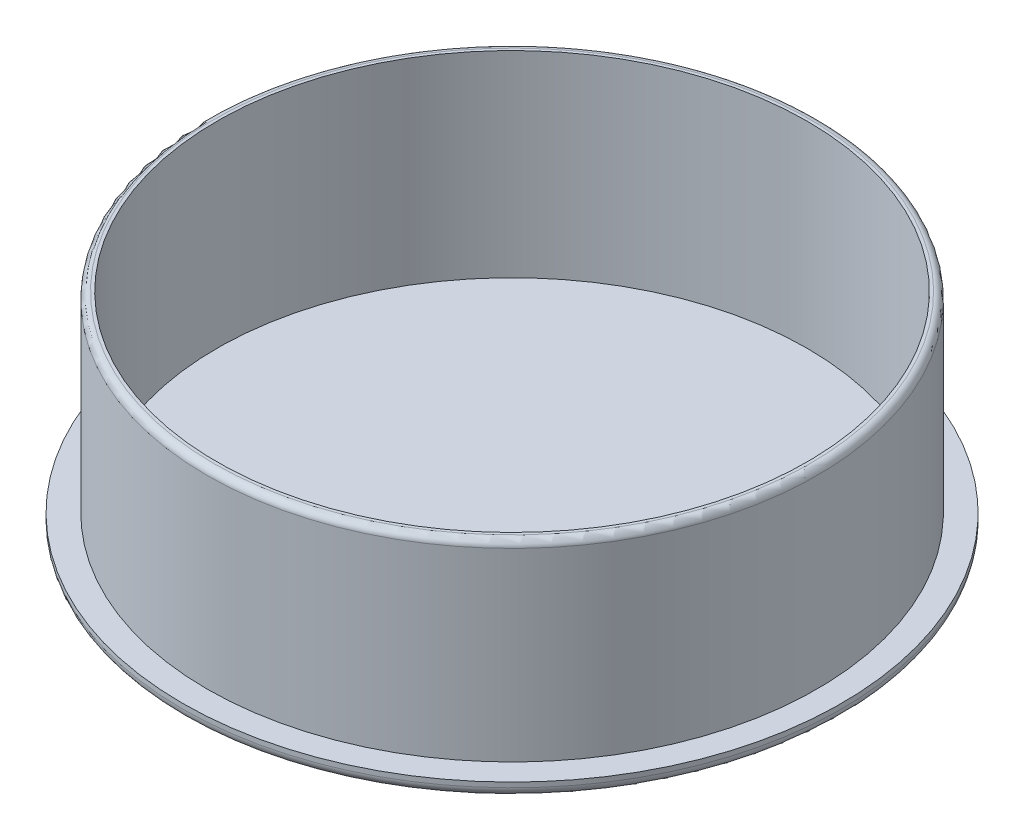
from build123d import *

# Parameters (mm, degrees)
SKETCH1_R           = 62
BOSS_EXTRUDE1_DEPTH = 42
SKETCH2_R           = 67
BOSS_EXTRUDE2_DEPTH = 3
FILLET1_R           = 2
SHELL1_T            = -2
FILLET2_R           = 1.4


with BuildPart() as part:
    # Sketch1 → Boss-Extrude1 (new body)
    with BuildSketch(Plane(origin=(0, 0, 0), x_dir=(1, 0, 0), z_dir=(0, 1, 0))):
        with Locations(Location((0, 0, 0), (0, 0, 90))):
            Circle(SKETCH1_R)
    extrude(amount=BOSS_EXTRUDE1_DEPTH)

    # Sketch2 → Boss-Extrude2 (add)
    with BuildSketch(Plane(origin=(0, 0, 0), x_dir=(1, 0, 0), z_dir=(0, 1, 0))):
        with Locations(Location((0, 0, 0), (0, 0, 270))):
            Circle(SKETCH2_R)
    extrude(amount=BOSS_EXTRUDE2_DEPTH)

    # Fillet1
    fillet1_edges = [part.edges().sort_by_distance(p)[0] for p in [
        (0, 0, -67),
    ]]
    fillet(fillet1_edges, radius=FILLET1_R)

    # Shell1
    shell1_openings = [part.faces().sort_by_distance(p)[0] for p in [
        (0, 42, 0),
    ]]
    offset(amount=SHELL1_T, openings=shell1_openings, kind=Kind.INTERSECTION)

    # Fillet2
    fillet2_edges = [part.edges().sort_by_distance(p)[0] for p in [
        (0, 42, 62),
    ]]
    fillet(fillet2_edges, radius=FILLET2_R)


solid = part.part
